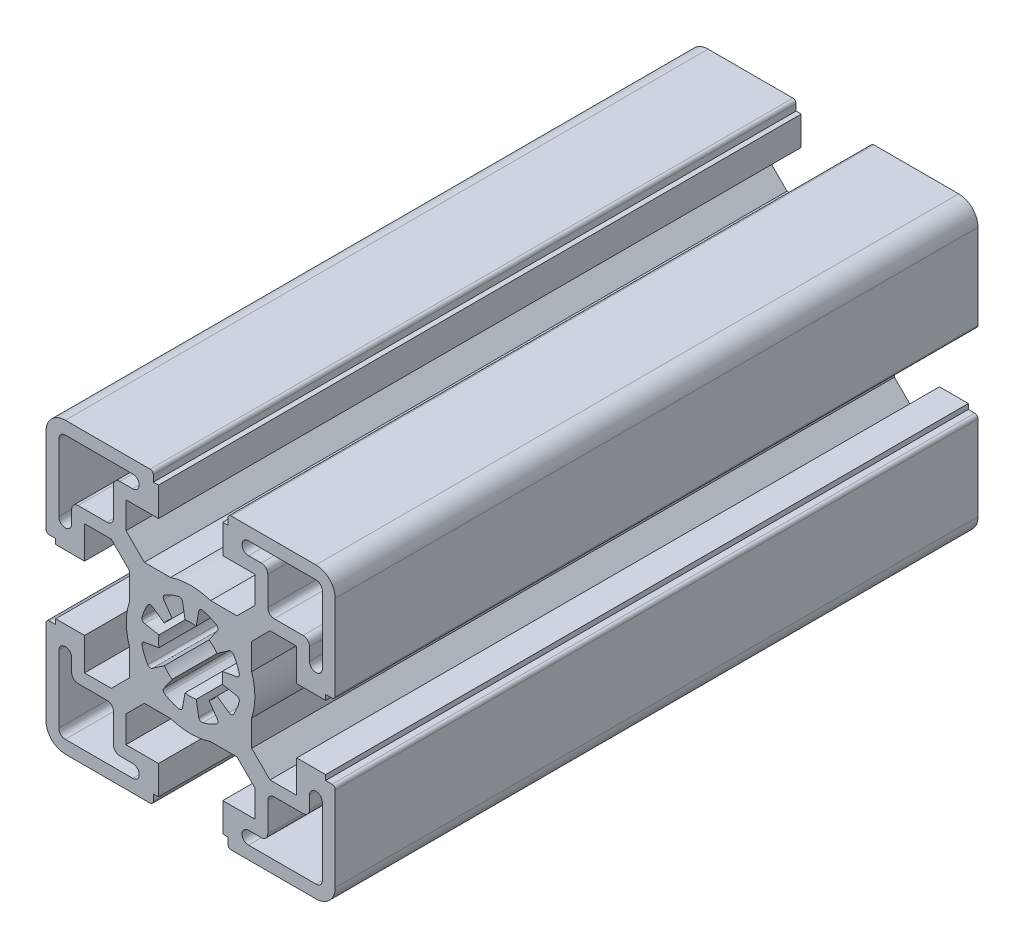
from build123d import *

# Parameters (mm, degrees)
BASE_EXTRUDE_DEPTH = 100


with BuildPart() as part:
    # Sketch1 → Base-Extrude (new body)
    with BuildSketch(Plane.XY):
        with BuildLine():
            Line((-4.99999574, -16.499883971), (-4.99999574, -20.99990968))
            Line((-4.99999574, -20.99990968), (-5.80004044, -20.99990968))
            Line((-5.80004044, -20.99990968), (-5.80004044, -21.999970054))
            ThreePointArc((-5.80004044, -21.999970054), (-5.946487232, -22.353523887), (-6.300041066, -22.49997068))
            Line((-6.300041066, -22.49997068), (-19.500014911, -22.49997068))
            ThreePointArc((-19.500014911, -22.49997068), (-21.62133367, -21.62129168), (-22.50001267, -19.499972921))
            Line((-22.50001267, -19.499972921), (-22.50001267, -6.299929564))
            ThreePointArc((-22.50001267, -6.299929564), (-22.353566213, -5.946376541), (-22.00001319, -5.799930084))
            Line((-22.00001319, -5.799930084), (-21.000012806, -5.799930084))
            Line((-21.000012806, -5.799930084), (-21.000012806, -4.999940084))
            Line((-21.000012806, -4.999940084), (-16.500012806, -4.999940084))
            Line((-16.500012806, -4.999940084), (-16.500012806, -10.049940084))
            Line((-16.500012806, -10.049940084), (-12.342923806, -10.049940084))
            Line((-12.342923806, -10.049940084), (-9.499953806, -7.206970084))
            Line((-9.499953806, -7.206970084), (-9.499953806, -3.122617084))
            ThreePointArc((-9.499953806, -3.122617084), (-10.000013376, 6.1916e-05), (-9.499953806, 3.122740916))
            Line((-9.499953806, 3.122740916), (-9.499953806, 7.206970084))
            Line((-9.499953806, 7.206970084), (-12.342923806, 10.049940084))
            Line((-12.342923806, 10.049940084), (-16.500012806, 10.049940084))
            Line((-16.500012806, 10.049940084), (-16.500012806, 4.999940084))
            Line((-16.500012806, 4.999940084), (-21.000012806, 4.999940084))
            Line((-21.000012806, 4.999940084), (-21.000012806, 5.799930084))
            Line((-21.000012806, 5.799930084), (-22.00001319, 5.799930084))
            ThreePointArc((-22.00001319, 5.799930084), (-22.353566213, 5.946376541), (-22.50001267, 6.299929564))
            Line((-22.50001267, 6.299929564), (-22.50001267, 19.499972921))
            ThreePointArc((-22.50001267, 19.499972921), (-21.62133367, 21.62129168), (-19.500014911, 22.49997068))
            Line((-19.500014911, 22.49997068), (-6.299954884, 22.49997068))
            ThreePointArc((-6.299954884, 22.49997068), (-5.946364566, 22.353508775), (-5.799902661, 21.999918456))
            Line((-5.799902661, 21.999918456), (-5.799902661, 20.999918083))
            Line((-5.799902661, 20.999918083), (-4.99999574, 20.999918083))
            Line((-4.99999574, 20.999918083), (-4.99999574, 16.499989166))
            Line((-4.99999574, 16.499989166), (-10.050086009, 16.499989166))
            Line((-10.050086009, 16.499989166), (-10.050086009, 12.342794971))
            Line((-10.050086009, 12.342794971), (-7.207151696, 9.499860659))
            Line((-7.207151696, 9.499860659), (-3.122798696, 9.499860659))
            ThreePointArc((-3.122798696, 9.499860659), (-0.000120196, 9.999920064), (3.122558304, 9.499860659))
            Line((3.122558304, 9.499860659), (7.206958901, 9.499860659))
            Line((7.206958901, 9.499860659), (10.049884116, 12.342787875))
            Line((10.049884116, 12.342787875), (10.049884116, 16.499989166))
            Line((10.049884116, 16.499989166), (4.99999574, 16.499989166))
            Line((4.99999574, 16.499989166), (4.99999574, 20.999963909))
            Line((4.99999574, 20.999963909), (5.799902661, 20.999963909))
            Line((5.799902661, 20.999963909), (5.799902661, 21.999918456))
            ThreePointArc((5.799902661, 21.999918456), (5.946364566, 22.353508775), (6.299954884, 22.49997068))
            Line((6.299954884, 22.49997068), (19.500081571, 22.49997068))
            ThreePointArc((19.500081571, 22.49997068), (21.62140033, 21.62129168), (22.50007933, 19.499972921))
            Line((22.50007933, 19.499972921), (22.50007933, 6.299877709))
            ThreePointArc((22.50007933, 6.299877709), (22.35363283, 5.946324583), (22.000079704, 5.799878083))
            Line((22.000079704, 5.799878083), (20.999995421, 5.799878083))
            Line((20.999995421, 5.799878083), (20.999995421, 4.999941084))
            Line((20.999995421, 4.999941084), (16.499983596, 4.999941084))
            Line((16.499983596, 4.999941084), (16.499983596, 10.049940084))
            Line((16.499983596, 10.049940084), (12.342894596, 10.049940084))
            Line((12.342894596, 10.049940084), (9.499922596, 7.206970084))
            Line((9.499922596, 7.206970084), (9.499922596, 3.122735916))
            ThreePointArc((9.499922596, 3.122735916), (9.999982165, 5.6916e-05), (9.499922596, -3.122622084))
            Line((9.499922596, -3.122622084), (9.499922596, -7.206970084))
            Line((9.499922596, -7.206970084), (12.342894596, -10.049940084))
            Line((12.342894596, -10.049940084), (16.499983596, -10.049940084))
            Line((16.499983596, -10.049940084), (16.499983596, -4.999941084))
            Line((16.499983596, -4.999941084), (20.999995421, -4.999941084))
            Line((20.999995421, -4.999941084), (20.999995421, -5.799878083))
            Line((20.999995421, -5.799878083), (22.000079704, -5.799878083))
            ThreePointArc((22.000079704, -5.799878083), (22.35363283, -5.946324583), (22.50007933, -6.299877709))
            Line((22.50007933, -6.299877709), (22.50007933, -19.499973421))
            ThreePointArc((22.50007933, -19.499973421), (21.621400476, -21.621291826), (19.500082071, -22.49997068))
            Line((19.500082071, -22.49997068), (6.300041066, -22.49997068))
            ThreePointArc((6.300041066, -22.49997068), (5.946487232, -22.353523887), (5.80004044, -21.999970054))
            Line((5.80004044, -21.999970054), (5.80004044, -20.99990968))
            Line((5.80004044, -20.99990968), (4.99999574, -20.99990968))
            Line((4.99999574, -20.99990968), (4.99999574, -16.499883971))
            Line((4.99999574, -16.499883971), (10.049884116, -16.499883971))
            Line((10.049884116, -16.499883971), (10.049884116, -12.342787875))
            Line((10.049884116, -12.342787875), (7.206933602, -9.49983536))
            Line((7.206933602, -9.49983536), (3.122579602, -9.49983536))
            ThreePointArc((3.122579602, -9.49983536), (-9.9398e-05, -9.99989493), (-3.122778398, -9.49983536))
            Line((-3.122778398, -9.49983536), (-7.207126398, -9.49983536))
            Line((-7.207126398, -9.49983536), (-10.050086009, -12.342794971))
            Line((-10.050086009, -12.342794971), (-10.050086009, -16.499883971))
            Line((-10.050086009, -16.499883971), (-4.99999574, -16.499883971))
        make_face()
        with BuildLine():
            Line((2.867879873, -4.095738521), (4.173655323, -5.960570749))
            ThreePointArc((4.173655323, -5.960570749), (4.253216568, -6.351019498), (4.022116912, -6.67563183))
            ThreePointArc((4.022116912, -6.67563183), (2.982522085, -7.200419904), (1.876337234, -7.564446005))
            ThreePointArc((1.876337234, -7.564446005), (1.483389354, -7.498323537), (1.263557864, -7.165976831))
            Line((1.263557864, -7.165976831), (0.868239441, -4.924019626))
            ThreePointArc((0.868239441, -4.924019626), (7.92e-06, -4.9999809), (-0.868223842, -4.924022376))
            Line((-0.868223842, -4.924022376), (-1.263535162, -7.165980833))
            ThreePointArc((-1.263535162, -7.165980833), (-1.483365599, -7.498328236), (-1.87631327, -7.564451949))
            ThreePointArc((-1.87631327, -7.564451949), (-2.982515957, -7.200422442), (-4.022126697, -6.675625934))
            ThreePointArc((-4.022126697, -6.675625934), (-4.253225878, -6.351013263), (-4.173664061, -5.960564631))
            Line((-4.173664061, -5.960564631), (-2.867885877, -4.095734317))
            ThreePointArc((-2.867885877, -4.095734317), (-3.535525782, -3.535515019), (-4.095743048, -2.867873408))
            Line((-4.095743048, -2.867873408), (-5.960577337, -4.173645915))
            ThreePointArc((-5.960577337, -4.173645915), (-6.351026211, -4.253206544), (-6.675638178, -4.022106375))
            ThreePointArc((-6.675638178, -4.022106375), (-7.200423154, -2.982514238), (-7.564447133, -1.876332686))
            ThreePointArc((-7.564447133, -1.876332686), (-7.498324428, -1.483384846), (-7.16597759, -1.263553556))
            Line((-7.16597759, -1.263553556), (-4.924020148, -0.868236481))
            ThreePointArc((-4.924020148, -0.868236481), (-4.9999809, 0), (-4.924020148, 0.868236481))
            Line((-4.924020148, 0.868236481), (-7.16597759, 1.263553556))
            ThreePointArc((-7.16597759, 1.263553556), (-7.498324428, 1.483384846), (-7.564447133, 1.876332686))
            ThreePointArc((-7.564447133, 1.876332686), (-7.200423154, 2.982514238), (-6.675638178, 4.022106375))
            ThreePointArc((-6.675638178, 4.022106375), (-6.351026211, 4.253206544), (-5.960577337, 4.173645915))
            Line((-5.960577337, 4.173645915), (-4.095743048, 2.867873408))
            ThreePointArc((-4.095743048, 2.867873408), (-3.535525782, 3.535515019), (-2.867885877, 4.095734317))
            Line((-2.867885877, 4.095734317), (-4.173664061, 5.960564631))
            ThreePointArc((-4.173664061, 5.960564631), (-4.253225878, 6.351013263), (-4.022126697, 6.675625934))
            ThreePointArc((-4.022126697, 6.675625934), (-2.982515957, 7.200422442), (-1.87631327, 7.564451949))
            ThreePointArc((-1.87631327, 7.564451949), (-1.483365599, 7.498328236), (-1.263535162, 7.165980833))
            Line((-1.263535162, 7.165980833), (-0.868223842, 4.924022376))
            ThreePointArc((-0.868223842, 4.924022376), (7.92e-06, 4.9999809), (0.868239441, 4.924019626))
            Line((0.868239441, 4.924019626), (1.263557864, 7.165976831))
            ThreePointArc((1.263557864, 7.165976831), (1.483389354, 7.498323537), (1.876337234, 7.564446005))
            ThreePointArc((1.876337234, 7.564446005), (2.982522085, 7.200419904), (4.022116912, 6.67563183))
            ThreePointArc((4.022116912, 6.67563183), (4.253216568, 6.351019498), (4.173655323, 5.960570749))
            Line((4.173655323, 5.960570749), (2.867879873, 4.095738521))
            ThreePointArc((2.867879873, 4.095738521), (3.535523556, 3.535517244), (4.095743641, 2.867872561))
            Line((4.095743641, 2.867872561), (5.9605782, 4.173644682))
            ThreePointArc((5.9605782, 4.173644682), (6.351027091, 4.25320523), (6.67563901, 4.022104994))
            ThreePointArc((6.67563901, 4.022104994), (7.200422982, 2.982514654), (7.564446528, 1.876335125))
            ThreePointArc((7.564446528, 1.876335125), (7.49832395, 1.483387263), (7.165977183, 1.263555866))
            Line((7.165977183, 1.263555866), (4.924019868, 0.868238068))
            ThreePointArc((4.924019868, 0.868238068), (4.9999809, 0), (4.924019868, -0.868238068))
            Line((4.924019868, -0.868238068), (7.165977183, -1.263555866))
            ThreePointArc((7.165977183, -1.263555866), (7.49832395, -1.483387263), (7.564446528, -1.876335125))
            ThreePointArc((7.564446528, -1.876335125), (7.200422982, -2.982514654), (6.67563901, -4.022104994))
            ThreePointArc((6.67563901, -4.022104994), (6.351027091, -4.25320523), (5.9605782, -4.173644682))
            Line((5.9605782, -4.173644682), (4.095743641, -2.867872561))
            ThreePointArc((4.095743641, -2.867872561), (3.535523556, -3.535517244), (2.867879873, -4.095738521))
        make_face(mode=Mode.SUBTRACT)
        with BuildLine():
            Line((-17.500118733, -12.000017917), (-13.000117238, -12.000017917))
            ThreePointArc((-13.000117238, -12.000017917), (-12.293010985, -12.292910917), (-12.000117985, -13.00001717))
            Line((-12.000117985, -13.00001717), (-12.000117985, -17.49992083))
            ThreePointArc((-12.000117985, -17.49992083), (-11.707224985, -18.207027083), (-11.000118733, -18.499920083))
            Line((-11.000118733, -18.499920083), (-9.000117985, -18.499920083))
            ThreePointArc((-9.000117985, -18.499920083), (-8.000069068, -19.499969), (-9.000117985, -20.500017917))
            Line((-9.000117985, -20.500017917), (-19.500118733, -20.500017917))
            ThreePointArc((-19.500118733, -20.500017917), (-20.207224985, -20.207124917), (-20.500117985, -19.500018664))
            Line((-20.500117985, -19.500018664), (-20.500117985, -8.999920083))
            ThreePointArc((-20.500117985, -8.999920083), (-19.500117985, -7.999920083), (-18.500117985, -8.999920083))
            Line((-18.500117985, -8.999920083), (-18.500117985, -11.000018664))
            ThreePointArc((-18.500117985, -11.000018664), (-18.207224985, -11.707124917), (-17.500118733, -12.000017917))
        make_face(mode=Mode.SUBTRACT)
        with BuildLine():
            Line((13.000003267, -12.000017917), (17.500004762, -12.000017917))
            ThreePointArc((17.500004762, -12.000017917), (18.207111015, -11.707124917), (18.500004015, -11.000018664))
            Line((18.500004015, -11.000018664), (18.500004015, -9.000115751))
            ThreePointArc((18.500004015, -9.000115751), (19.500004015, -8.000115751), (20.500004015, -9.000115751))
            Line((20.500004015, -9.000115751), (20.500004015, -19.500018664))
            ThreePointArc((20.500004015, -19.500018664), (20.207111015, -20.207124917), (19.500004762, -20.500017917))
            Line((19.500004762, -20.500017917), (9.000004015, -20.500017917))
            ThreePointArc((9.000004015, -20.500017917), (7.999955097, -19.499969), (9.000004015, -18.499920083))
            Line((9.000004015, -18.499920083), (11.000004762, -18.499920083))
            ThreePointArc((11.000004762, -18.499920083), (11.707111015, -18.207027083), (12.000004015, -17.49992083))
            Line((12.000004015, -17.49992083), (12.000004015, -13.00001717))
            ThreePointArc((12.000004015, -13.00001717), (12.292897015, -12.292910917), (13.000003267, -12.000017917))
        make_face(mode=Mode.SUBTRACT)
        with BuildLine():
            Line((-17.500118733, 12.000017917), (-13.000117238, 12.000017917))
            ThreePointArc((-13.000117238, 12.000017917), (-12.293010985, 12.292910917), (-12.000117985, 13.00001717))
            Line((-12.000117985, 13.00001717), (-12.000117985, 17.49992083))
            ThreePointArc((-12.000117985, 17.49992083), (-11.707224985, 18.207027083), (-11.000118733, 18.499920083))
            Line((-11.000118733, 18.499920083), (-9.000117985, 18.499920083))
            ThreePointArc((-9.000117985, 18.499920083), (-8.000069068, 19.499969), (-9.000117985, 20.500017917))
            Line((-9.000117985, 20.500017917), (-19.500118733, 20.500017917))
            ThreePointArc((-19.500118733, 20.500017917), (-20.207224985, 20.207124917), (-20.500117985, 19.500018664))
            Line((-20.500117985, 19.500018664), (-20.500117985, 8.999920083))
            ThreePointArc((-20.500117985, 8.999920083), (-19.500117985, 7.999920083), (-18.500117985, 8.999920083))
            Line((-18.500117985, 8.999920083), (-18.500117985, 11.000018664))
            ThreePointArc((-18.500117985, 11.000018664), (-18.207224985, 11.707124917), (-17.500118733, 12.000017917))
        make_face(mode=Mode.SUBTRACT)
        with BuildLine():
            Line((13.000003267, 12.000017917), (17.500004762, 12.000017917))
            ThreePointArc((17.500004762, 12.000017917), (18.207111015, 11.707124917), (18.500004015, 11.000018664))
            Line((18.500004015, 11.000018664), (18.500004015, 9.000115751))
            ThreePointArc((18.500004015, 9.000115751), (19.500004015, 8.000115751), (20.500004015, 9.000115751))
            Line((20.500004015, 9.000115751), (20.500004015, 19.500018664))
            ThreePointArc((20.500004015, 19.500018664), (20.207111015, 20.207124917), (19.500004762, 20.500017917))
            Line((19.500004762, 20.500017917), (9.000004015, 20.500017917))
            ThreePointArc((9.000004015, 20.500017917), (7.999955097, 19.499969), (9.000004015, 18.499920083))
            Line((9.000004015, 18.499920083), (11.000004762, 18.499920083))
            ThreePointArc((11.000004762, 18.499920083), (11.707111015, 18.207027083), (12.000004015, 17.49992083))
            Line((12.000004015, 17.49992083), (12.000004015, 13.00001717))
            ThreePointArc((12.000004015, 13.00001717), (12.292897015, 12.292910917), (13.000003267, 12.000017917))
        make_face(mode=Mode.SUBTRACT)
    extrude(amount=BASE_EXTRUDE_DEPTH)


solid = part.part
